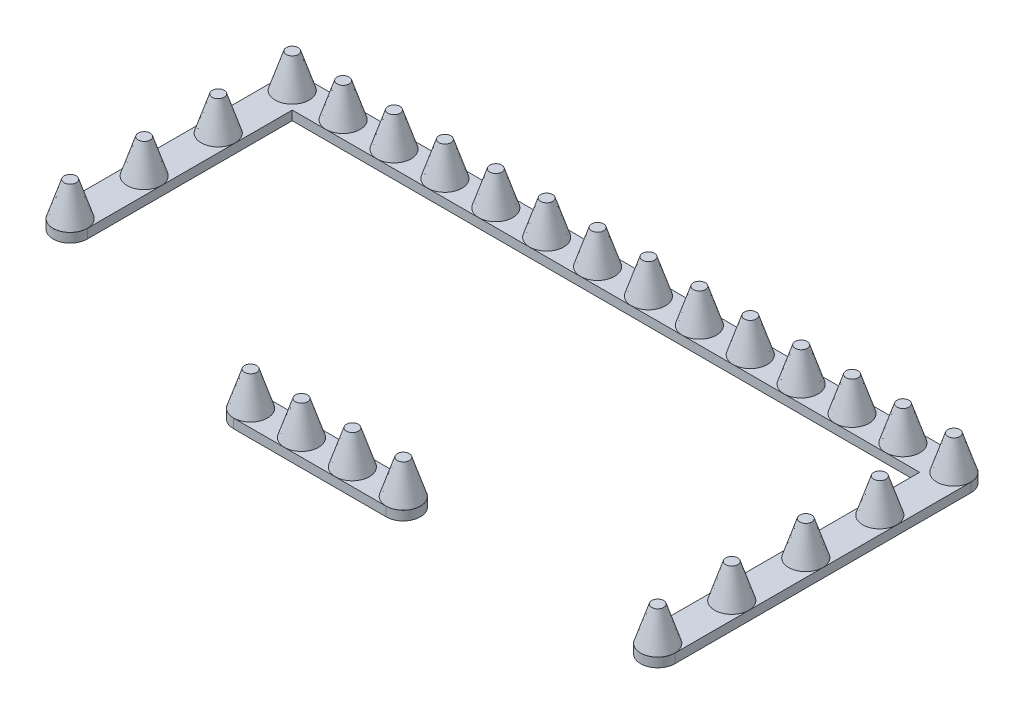
from build123d import *

# Parameters (mm, degrees)
PATTERN_LINEAR_3_COUNT = 4
PATTERN_LINEAR_3_PITCH = 160
PATTERN_LINEAR_4_COUNT = 14
PATTERN_LINEAR_4_PITCH = 110
PATTERN_LINEAR_5_COUNT = 5
PATTERN_LINEAR_5_PITCH = 160
PATTERN_LINEAR_6_COUNT = 2
PATTERN_LINEAR_6_PITCH = 550
PATTERN_LINEAR_7_COUNT = 4
PATTERN_LINEAR_7_PITCH = 110
EXTRUDE_3_DEPTH        = 20


with BuildPart() as part:
    # 草图2 → 旋转1 (revolve)
    with BuildSketch(Plane.XY):
        Polygon((0, -0.545321134), (0, 73.454678866), (13, 73.454678866), (37, -0.545321134), align=None)
    revolve(axis=Axis((0, -0.545321134, 0), (0, 1, 0)))


with BuildPart() as pattern_linear_3_1:
    # 阵列(线性)3: pattern copy
    add(part.part.moved(Location(Vector(0, 0, 1) * (1 * PATTERN_LINEAR_3_PITCH))))


with BuildPart() as pattern_linear_3_2:
    # 阵列(线性)3: pattern copy
    add(part.part.moved(Location(Vector(0, 0, 1) * (2 * PATTERN_LINEAR_3_PITCH))))


with BuildPart() as pattern_linear_3_3:
    # 阵列(线性)3: pattern copy
    add(part.part.moved(Location(Vector(0, 0, 1) * (3 * PATTERN_LINEAR_3_PITCH))))


with BuildPart() as pattern_linear_4_1:
    # 阵列(线性)4: pattern copy
    add(part.part.moved(Location(Vector(1, 0, 0) * (1 * PATTERN_LINEAR_4_PITCH))))


with BuildPart() as pattern_linear_4_2:
    # 阵列(线性)4: pattern copy
    add(part.part.moved(Location(Vector(1, 0, 0) * (2 * PATTERN_LINEAR_4_PITCH))))


with BuildPart() as pattern_linear_4_3:
    # 阵列(线性)4: pattern copy
    add(part.part.moved(Location(Vector(1, 0, 0) * (3 * PATTERN_LINEAR_4_PITCH))))


with BuildPart() as pattern_linear_4_4:
    # 阵列(线性)4: pattern copy
    add(part.part.moved(Location(Vector(1, 0, 0) * (4 * PATTERN_LINEAR_4_PITCH))))


with BuildPart() as pattern_linear_4_5:
    # 阵列(线性)4: pattern copy
    add(part.part.moved(Location(Vector(1, 0, 0) * (5 * PATTERN_LINEAR_4_PITCH))))


with BuildPart() as pattern_linear_4_6:
    # 阵列(线性)4: pattern copy
    add(part.part.moved(Location(Vector(1, 0, 0) * (6 * PATTERN_LINEAR_4_PITCH))))


with BuildPart() as pattern_linear_4_7:
    # 阵列(线性)4: pattern copy
    add(part.part.moved(Location(Vector(1, 0, 0) * (7 * PATTERN_LINEAR_4_PITCH))))


with BuildPart() as pattern_linear_4_8:
    # 阵列(线性)4: pattern copy
    add(part.part.moved(Location(Vector(1, 0, 0) * (8 * PATTERN_LINEAR_4_PITCH))))


with BuildPart() as pattern_linear_4_9:
    # 阵列(线性)4: pattern copy
    add(part.part.moved(Location(Vector(1, 0, 0) * (9 * PATTERN_LINEAR_4_PITCH))))


with BuildPart() as pattern_linear_4_10:
    # 阵列(线性)4: pattern copy
    add(part.part.moved(Location(Vector(1, 0, 0) * (10 * PATTERN_LINEAR_4_PITCH))))


with BuildPart() as pattern_linear_4_11:
    # 阵列(线性)4: pattern copy
    add(part.part.moved(Location(Vector(1, 0, 0) * (11 * PATTERN_LINEAR_4_PITCH))))


with BuildPart() as pattern_linear_4_12:
    # 阵列(线性)4: pattern copy
    add(part.part.moved(Location(Vector(1, 0, 0) * (12 * PATTERN_LINEAR_4_PITCH))))


with BuildPart() as pattern_linear_4_13:
    # 阵列(线性)4: pattern copy
    add(part.part.moved(Location(Vector(1, 0, 0) * (13 * PATTERN_LINEAR_4_PITCH))))


with BuildPart() as pattern_linear_5_1:
    # 阵列(线性)5: pattern copy
    add(pattern_linear_4_13.part.moved(Location(Vector(0, 0, 1) * (1 * PATTERN_LINEAR_5_PITCH))))


with BuildPart() as pattern_linear_5_2:
    # 阵列(线性)5: pattern copy
    add(pattern_linear_4_13.part.moved(Location(Vector(0, 0, 1) * (2 * PATTERN_LINEAR_5_PITCH))))


with BuildPart() as pattern_linear_5_3:
    # 阵列(线性)5: pattern copy
    add(pattern_linear_4_13.part.moved(Location(Vector(0, 0, 1) * (3 * PATTERN_LINEAR_5_PITCH))))


with BuildPart() as pattern_linear_5_4:
    # 阵列(线性)5: pattern copy
    add(pattern_linear_4_13.part.moved(Location(Vector(0, 0, 1) * (4 * PATTERN_LINEAR_5_PITCH))))


with BuildPart() as pattern_linear_6_1:
    # 阵列(线性)6: pattern copy
    add(pattern_linear_5_4.part.moved(Location(Vector(-1, 0, 0) * (1 * PATTERN_LINEAR_6_PITCH))))


with BuildPart() as pattern_linear_7_1:
    # 阵列(线性)7: pattern copy
    add(pattern_linear_6_1.part.moved(Location(Vector(-1, 0, 0) * (1 * PATTERN_LINEAR_7_PITCH))))


with BuildPart() as pattern_linear_7_2:
    # 阵列(线性)7: pattern copy
    add(pattern_linear_6_1.part.moved(Location(Vector(-1, 0, 0) * (2 * PATTERN_LINEAR_7_PITCH))))


with BuildPart() as pattern_linear_7_3:
    # 阵列(线性)7: pattern copy
    add(pattern_linear_6_1.part.moved(Location(Vector(-1, 0, 0) * (3 * PATTERN_LINEAR_7_PITCH))))


with BuildPart() as part_1:
    add(part.part)

    add(pattern_linear_3_1.part)  # 凸台-拉伸3 merges 阵列(线性)3_1

    add(pattern_linear_3_2.part)  # 凸台-拉伸3 merges 阵列(线性)3_2

    add(pattern_linear_3_3.part)  # 凸台-拉伸3 merges 阵列(线性)3_3

    add(pattern_linear_4_1.part)  # 凸台-拉伸3 merges 阵列(线性)4_1

    add(pattern_linear_4_2.part)  # 凸台-拉伸3 merges 阵列(线性)4_2

    add(pattern_linear_4_3.part)  # 凸台-拉伸3 merges 阵列(线性)4_3

    add(pattern_linear_4_4.part)  # 凸台-拉伸3 merges 阵列(线性)4_4

    add(pattern_linear_4_5.part)  # 凸台-拉伸3 merges 阵列(线性)4_5

    add(pattern_linear_4_6.part)  # 凸台-拉伸3 merges 阵列(线性)4_6

    add(pattern_linear_4_7.part)  # 凸台-拉伸3 merges 阵列(线性)4_7

    add(pattern_linear_4_8.part)  # 凸台-拉伸3 merges 阵列(线性)4_8

    add(pattern_linear_4_9.part)  # 凸台-拉伸3 merges 阵列(线性)4_9

    add(pattern_linear_4_10.part)  # 凸台-拉伸3 merges 阵列(线性)4_10

    add(pattern_linear_4_11.part)  # 凸台-拉伸3 merges 阵列(线性)4_11

    add(pattern_linear_4_12.part)  # 凸台-拉伸3 merges 阵列(线性)4_12

    add(pattern_linear_4_13.part)  # 凸台-拉伸3 merges 阵列(线性)4_13

    add(pattern_linear_5_1.part)  # 凸台-拉伸3 merges 阵列(线性)5_1

    add(pattern_linear_5_2.part)  # 凸台-拉伸3 merges 阵列(线性)5_2

    add(pattern_linear_5_3.part)  # 凸台-拉伸3 merges 阵列(线性)5_3

    add(pattern_linear_5_4.part)  # 凸台-拉伸3 merges 阵列(线性)5_4

    add(pattern_linear_6_1.part)  # 凸台-拉伸3 merges 阵列(线性)6_1

    add(pattern_linear_7_1.part)  # 凸台-拉伸3 merges 阵列(线性)7_1

    add(pattern_linear_7_2.part)  # 凸台-拉伸3 merges 阵列(线性)7_2

    add(pattern_linear_7_3.part)  # 凸台-拉伸3 merges 阵列(线性)7_3
    # 草图5 → 凸台-拉伸3 (add)
    with BuildSketch(Plane(origin=(0, 0, 0), x_dir=(1, 0, 0), z_dir=(0, 1, 0))):
        with BuildLine():
            Line((37, -480), (37, -37))
            Line((37, -37), (1393, -37))
            Line((1393, -37), (1393, -640))
            ThreePointArc((1393, -640), (1430, -677), (1467, -640))
            Line((1467, -640), (1467, 0))
            ThreePointArc((1467, 0), (1456.162950904, 26.162950904), (1430, 37))
            Line((1430, 37), (0, 37))
            ThreePointArc((0, 37), (-26.162950904, 26.162950904), (-37, 0))
            Line((-37, 0), (-37, -480))
            ThreePointArc((-37, -480), (0, -517), (37, -480))
        make_face()
        with BuildLine():
            Line((550, -677), (880, -677))
            ThreePointArc((880, -677), (917, -640), (880, -603))
            Line((880, -603), (550, -603))
            ThreePointArc((550, -603), (513, -640), (550, -677))
        make_face()
    extrude(amount=-EXTRUDE_3_DEPTH)


solid = part_1.part
